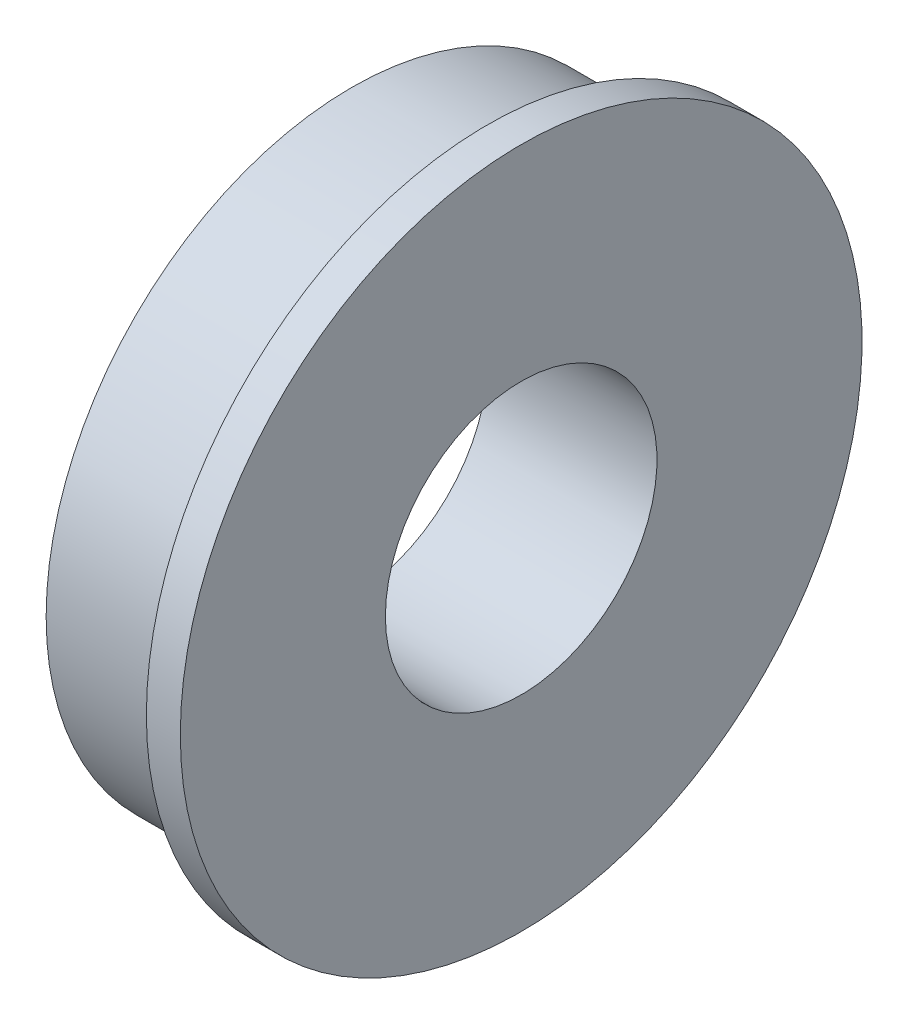
from build123d import *


with BuildPart() as part:
    # Sketch1 → Revolve1 (revolve)
    with BuildSketch(Plane.XY):
        Polygon((7.9248, 6.35), (0, 6.35), (0, 14.2875), (6.3373, 14.2875), (6.3373, 15.9385), (7.9248, 15.9385), align=None)
    revolve(axis=Axis((0, 0, 0), (1, 0, 0)))


solid = part.part
